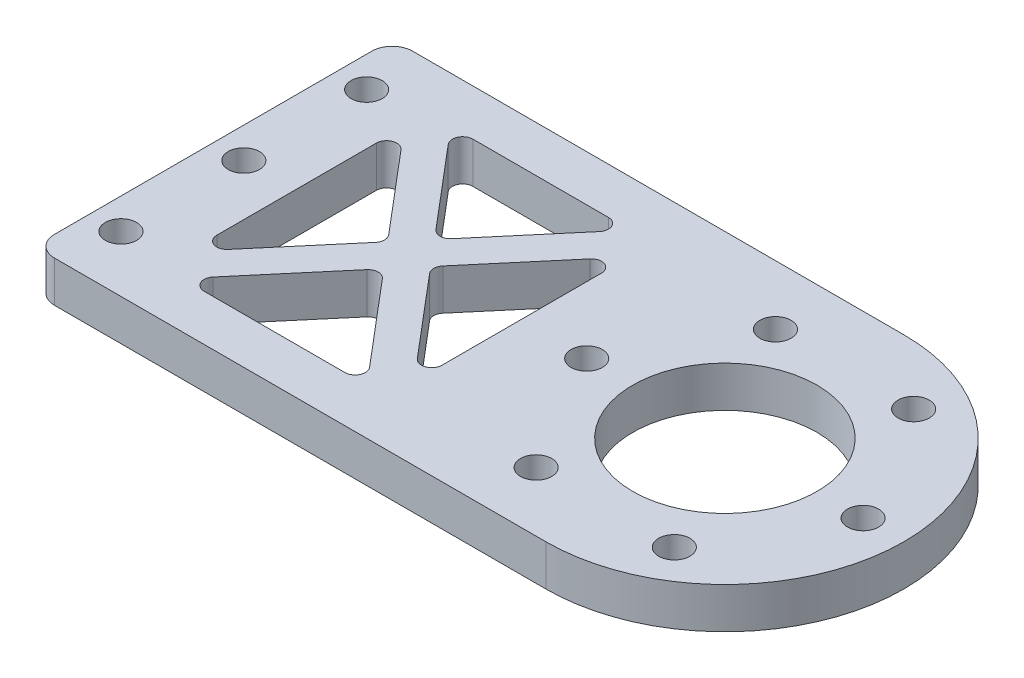
from build123d import *

# Parameters (mm, degrees)
EXTRUDE_1_DEPTH     = 4
SKETCH_3_R          = 1.525
CUT_EXTRUDE_2_DEPTH = 5
SKETCH_4_R          = 9
CUT_EXTRUDE_3_DEPTH = 5
CUT_EXTRUDE_4_DEPTH = 5
FILLET_1_R          = 1
FILLET_2_R          = 2
SKETCH_7_R          = 1.525
CUT_EXTRUDE_5_DEPTH = 5


with BuildPart() as part:
    # 草图1 → 凸台-拉伸1 (new body)
    with BuildSketch(Plane(origin=(0, 0, 0), x_dir=(1, 0, 0), z_dir=(0, 1, 0))):
        with BuildLine():
            Line((-25, 17.5), (-25, -17.5))
            Line((-25, -17.5), (25, -17.5))
            ThreePointArc((25, -17.5), (7.5, 0), (25, 17.5))
            Line((25, 17.5), (-25, 17.5))
        make_face()
        with BuildLine():
            ThreePointArc((25, 17.5), (7.5, 0), (25, -17.5))
            Line((25, -17.5), (25, 17.5))
        make_face()
        with BuildLine():
            Line((25, 17.5), (25, -17.5))
            ThreePointArc((25, -17.5), (37.374368671, -12.374368671), (42.5, 0))
            ThreePointArc((42.5, 0), (37.374368671, 12.374368671), (25, 17.5))
        make_face()
    extrude(amount=EXTRUDE_1_DEPTH)

    # 草图3 → 切除-拉伸2 (cut, through all)
    with BuildSketch(Plane(origin=(0, 4, 0), x_dir=(1, 0, 0), z_dir=(0, 1, 0))):
        with Locations((38.5, 0)):
            Circle(SKETCH_3_R)
        with Locations((31.75, -11.691342951)):
            Circle(SKETCH_3_R)
        with Locations((18.25, -11.691342951)):
            Circle(SKETCH_3_R)
        with Locations((11.5, 0)):
            Circle(SKETCH_3_R)
        with Locations((18.25, 11.691342951)):
            Circle(SKETCH_3_R)
        with Locations((31.75, 11.691342951)):
            Circle(SKETCH_3_R)
    extrude(amount=-CUT_EXTRUDE_2_DEPTH, mode=Mode.SUBTRACT)

    # 草图4 → 切除-拉伸3 (cut, through all)
    with BuildSketch(Plane(origin=(0, 4, 0), x_dir=(1, 0, 0), z_dir=(0, 1, 0))):
        with Locations((25, 0)):
            Circle(SKETCH_4_R)
    extrude(amount=-CUT_EXTRUDE_3_DEPTH, mode=Mode.SUBTRACT)

    # 草图5 → 切除-拉伸4 (cut, through all)
    with BuildSketch(Plane(origin=(0, 4, 0), x_dir=(1, 0, 0), z_dir=(0, 1, 0))):
        Polygon((-14.773080244, 13), (-6, 2.631814257), (2.773080244, 13), align=None)
        Polygon((5, 10.67781095), (-3.904075524, 0.154812603), (5, -10.368185743), align=None)
        Polygon((-6, -2.32218905), (-15.035070804, -13), (3.035070804, -13), align=None)
        Polygon((-17, 10.67781095), (-17, -10.368185743), (-8.095924476, 0.154812603), align=None)
    extrude(amount=-CUT_EXTRUDE_4_DEPTH, mode=Mode.SUBTRACT)

    # 圆角1
    fillet_1_edges = [part.edges().sort_by_distance(p)[0] for p in [
        (-15.035070804, 2, 13),
        (-6, 2, 2.32218905),
        (3.035070804, 2, 13),
        (-3.904075524, 2, -0.154812603),
        (5, 2, -10.67781095),
        (5, 2, 10.368185743),
        (-17, 2, 10.368185743),
        (-17, 2, -10.67781095),
        (-8.095924476, 2, -0.154812603),
        (-6, 2, -2.631814257),
        (-14.773080244, 2, -13),
        (2.773080244, 2, -13),
    ]]
    fillet(fillet_1_edges, radius=FILLET_1_R)

    # 圆角2
    fillet_2_edges = [part.edges().sort_by_distance(p)[0] for p in [
        (-25, 2, 17.5),
        (-25, 2, -17.5),
    ]]
    fillet(fillet_2_edges, radius=FILLET_2_R)

    # 草图7 → 切除-拉伸5 (cut, through all)
    with BuildSketch(Plane(origin=(0, 4, 0), x_dir=(1, 0, 0), z_dir=(0, 1, 0))):
        with Locations((-22, 0)):
            Circle(SKETCH_7_R)
        with Locations((-22, 12)):
            Circle(SKETCH_7_R)
        with Locations((-22, -12)):
            Circle(SKETCH_7_R)
    extrude(amount=-CUT_EXTRUDE_5_DEPTH, mode=Mode.SUBTRACT)


solid = part.part
